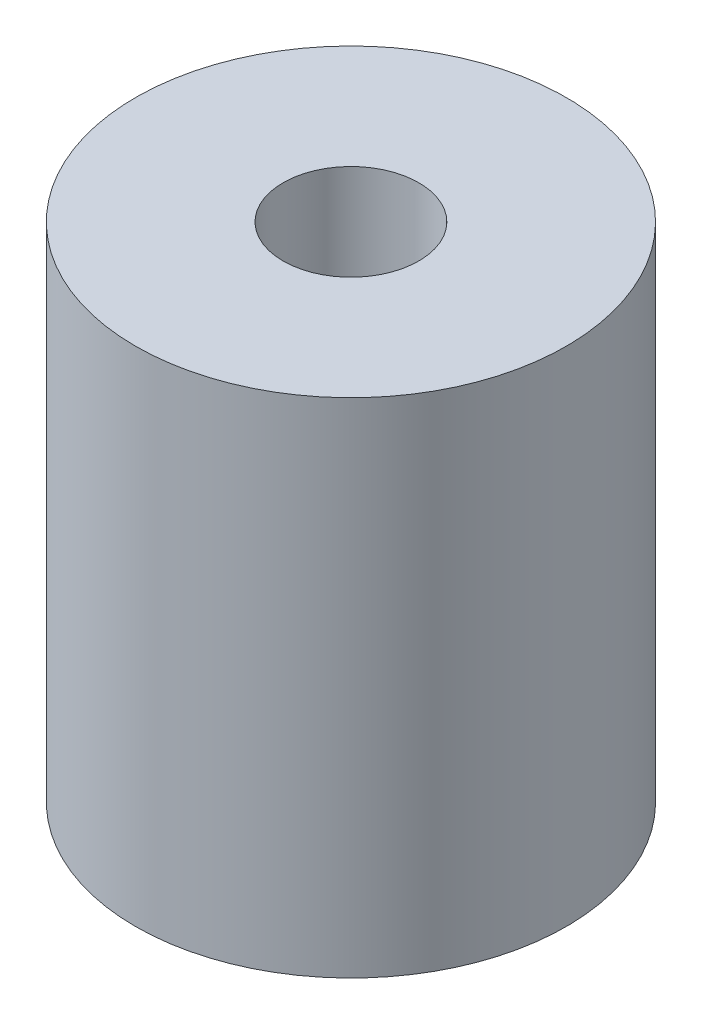
from build123d import *

# Parameters (mm, degrees)
SKETCH1_R      = 4.7625
SKETCH1_R_2    = 1.5
EXTRUDE1_DEPTH = 11.1125


with BuildPart() as part:
    # Sketch1 → Extrude1 (new body)
    with BuildSketch(Plane(origin=(0, 0, 0), x_dir=(1, 0, 0), z_dir=(0, 1, 0))):
        Circle(SKETCH1_R)
        Circle(SKETCH1_R_2, mode=Mode.SUBTRACT)
    extrude(amount=-EXTRUDE1_DEPTH)


solid = part.part
